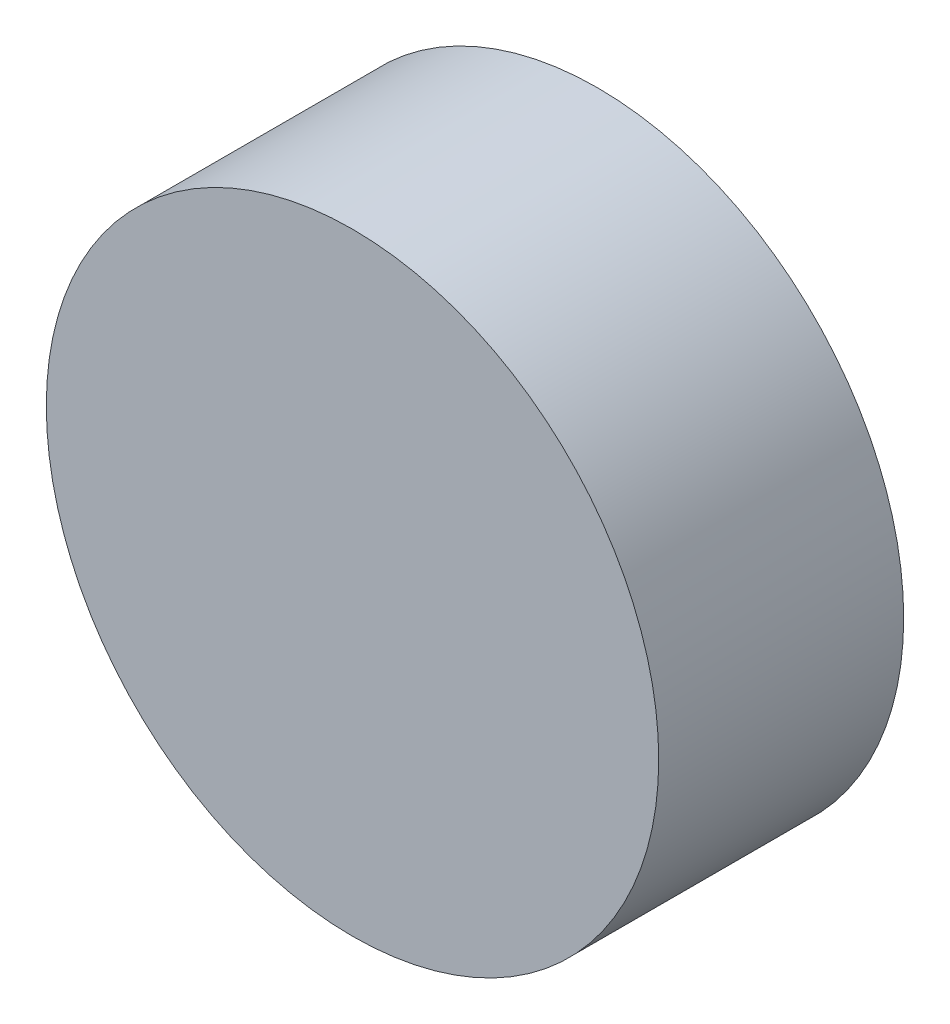
from build123d import *

# Parameters (mm, degrees)
SKETCH1_R           = 2.5
BOSS_EXTRUDE1_DEPTH = 2


with BuildPart() as part:
    # Sketch1 → Boss-Extrude1 (new body)
    with BuildSketch(Plane.XY):
        Circle(SKETCH1_R)
    extrude(amount=BOSS_EXTRUDE1_DEPTH)


solid = part.part
